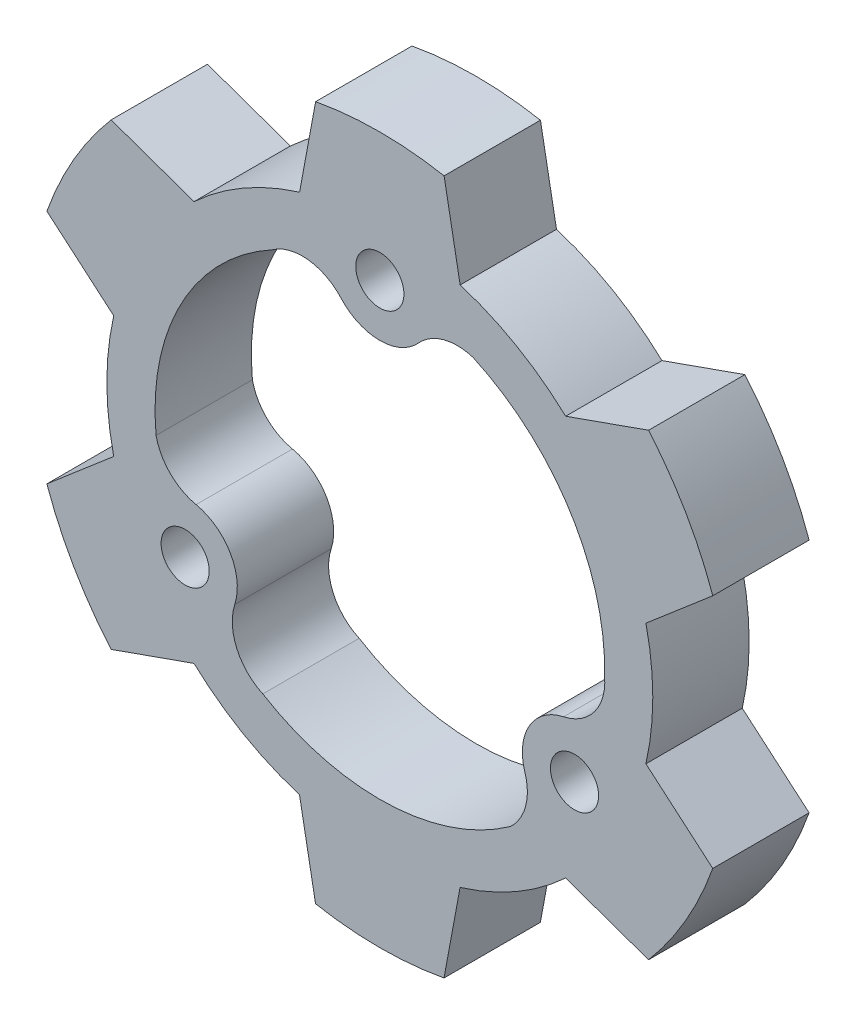
from build123d import *

# Parameters (mm, degrees)
ESQUISSE1_R        = 1.5
BOSS_EXTRU_2_DEPTH = 6


with BuildPart() as part:
    # Esquisse1 → Boss.-Extru.2 (new body)
    with BuildSketch(Plane.XY):
        with BuildLine():
            Line((-4.997277712, 16.248914286), (-3.997277712, 21.633810827))
            ThreePointArc((-3.997277712, 21.633810827), (0.002768431, 21.999999826), (4.002722288, 21.632804124))
            Line((4.002722288, 21.632804124), (5.002722288, 16.247238834))
            ThreePointArc((5.002722288, 16.247238834), (8.502466554, 14.721007523), (11.573333699, 12.452226592))
            Line((11.573333699, 12.452226592), (16.7367909, 14.278649458))
            ThreePointArc((16.7367909, 14.278649458), (19.053942948, 10.997602381), (20.735919071, 7.349942877))
            Line((20.735919071, 7.349942877), (16.571882715, 3.791134828))
            ThreePointArc((16.571882715, 3.791134828), (16.999999761, -0.002848269), (16.570611412, -3.796687694))
            Line((16.570611412, -3.796687694), (20.734068613, -7.355161368))
            ThreePointArc((20.734068613, -7.355161368), (19.051174517, -11.002397445), (16.733196783, -14.282861248))
            Line((16.733196783, -14.282861248), (11.569160427, -12.456104006))
            ThreePointArc((11.569160427, -12.456104006), (8.497533208, -14.723855792), (4.997277712, -16.248914286))
            Line((4.997277712, -16.248914286), (3.997277712, -21.633810827))
            ThreePointArc((3.997277712, -21.633810827), (-0.002768431, -21.999999826), (-4.002722288, -21.632804124))
            Line((-4.002722288, -21.632804124), (-5.002722288, -16.247238834))
            ThreePointArc((-5.002722288, -16.247238834), (-8.502466554, -14.721007523), (-11.573333699, -12.452226592))
            Line((-11.573333699, -12.452226592), (-16.7367909, -14.278649458))
            ThreePointArc((-16.7367909, -14.278649458), (-19.053942948, -10.997602381), (-20.735919071, -7.349942877))
            Line((-20.735919071, -7.349942877), (-16.571882715, -3.791134828))
            ThreePointArc((-16.571882715, -3.791134828), (-16.999999761, 0.002848269), (-16.570611412, 3.796687694))
            Line((-16.570611412, 3.796687694), (-20.734068613, 7.355161368))
            ThreePointArc((-20.734068613, 7.355161368), (-19.051174517, 11.002397445), (-16.733196783, 14.282861248))
            Line((-16.733196783, 14.282861248), (-11.569160427, 12.456104006))
            ThreePointArc((-11.569160427, 12.456104006), (-8.497533208, 14.723855792), (-4.997277712, 16.248914286))
        make_face()
        with Locations((0, 14)):
            Circle(ESQUISSE1_R, mode=Mode.SUBTRACT)
        with Locations((12.124355653, -7)):
            Circle(ESQUISSE1_R, mode=Mode.SUBTRACT)
        with Locations((-12.124355653, -7)):
            Circle(ESQUISSE1_R, mode=Mode.SUBTRACT)
        with BuildLine():
            ThreePointArc((-2.411034891, 11.820685714), (0, 10.75), (2.411034891, 11.820685714))
            ThreePointArc((2.411034891, 11.820685714), (3.975330286, 12.779130538), (5.80943088, 12.737759334))
            ThreePointArc((5.80943088, 12.737759334), (11.865562564, 7.430237213), (13.995977593, -0.335575935))
            ThreePointArc((13.995977593, -0.335575935), (13.382779595, -2.564868949), (11.442531564, -3.822325392))
            ThreePointArc((11.442531564, -3.822325392), (9.309773091, -5.375), (9.031496673, -7.998360322))
            ThreePointArc((9.031496673, -7.998360322), (9.079386541, -9.832302285), (8.126507731, -11.399994391))
            ThreePointArc((8.126507731, -11.399994391), (0.5019929, -13.990997217), (-7.288606081, -11.953084179))
            ThreePointArc((-7.288606081, -11.953084179), (-8.912631465, -10.307392628), (-9.031496673, -7.998360322))
            ThreePointArc((-9.031496673, -7.998360322), (-9.309773091, -5.375), (-11.442531564, -3.822325392))
            ThreePointArc((-11.442531564, -3.822325392), (-13.054716827, -2.946828253), (-13.935938611, -1.337764944))
            ThreePointArc((-13.935938611, -1.337764944), (-12.367555464, 6.560760004), (-6.707371512, 12.288660114))
            ThreePointArc((-6.707371512, 12.288660114), (-4.47014813, 12.872261577), (-2.411034891, 11.820685714))
        make_face(mode=Mode.SUBTRACT)
    extrude(amount=BOSS_EXTRU_2_DEPTH)


solid = part.part
